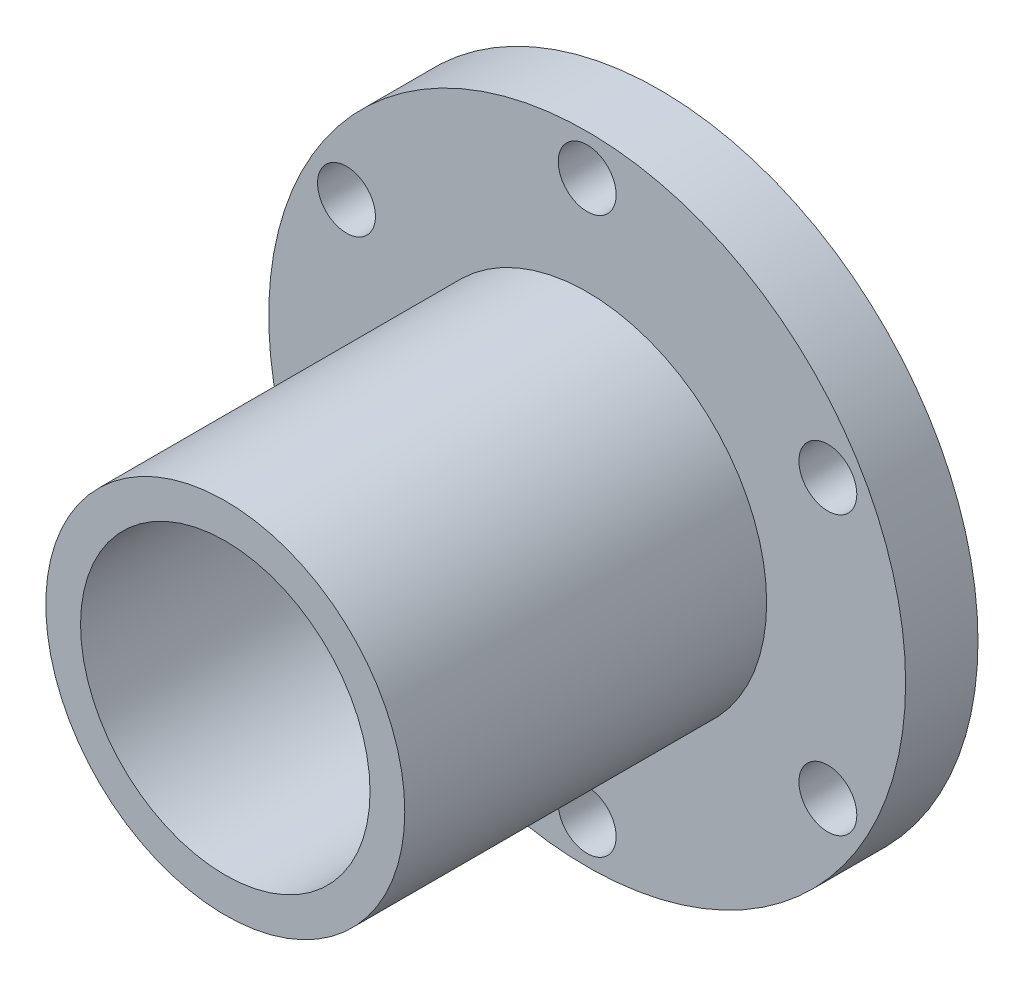
from build123d import *

# Parameters (mm, degrees)
SKETCH1_R           = 110
SKETCH1_R_2         = 10
BOSS_EXTRUDE1_DEPTH = 25
SKETCH2_R           = 62
BOSS_EXTRUDE2_DEPTH = 125
SKETCH3_R           = 50
CUT_EXTRUDE1_DEPTH  = 151


with BuildPart() as part:
    # Sketch1 → Boss-Extrude1 (new body)
    with BuildSketch(Plane.XY):
        Circle(SKETCH1_R)
        with Locations((0, -96)):
            Circle(SKETCH1_R_2, mode=Mode.SUBTRACT)
        with Locations((-83.138438763, -48)):
            Circle(SKETCH1_R_2, mode=Mode.SUBTRACT)
        with Locations((-83.138438763, 48)):
            Circle(SKETCH1_R_2, mode=Mode.SUBTRACT)
        with Locations((0, 96)):
            Circle(SKETCH1_R_2, mode=Mode.SUBTRACT)
        with Locations((83.138438763, 48)):
            Circle(SKETCH1_R_2, mode=Mode.SUBTRACT)
        with Locations((83.138438763, -48)):
            Circle(SKETCH1_R_2, mode=Mode.SUBTRACT)
    extrude(amount=BOSS_EXTRUDE1_DEPTH)

    # Sketch2 → Boss-Extrude2 (add)
    with BuildSketch(Plane.XY.offset(25)):
        Circle(SKETCH2_R)
    extrude(amount=BOSS_EXTRUDE2_DEPTH)

    # Sketch3 → Cut-Extrude1 (cut, through all)
    with BuildSketch(Plane.XY.offset(150)):
        Circle(SKETCH3_R)
    extrude(amount=-CUT_EXTRUDE1_DEPTH, mode=Mode.SUBTRACT)


solid = part.part
